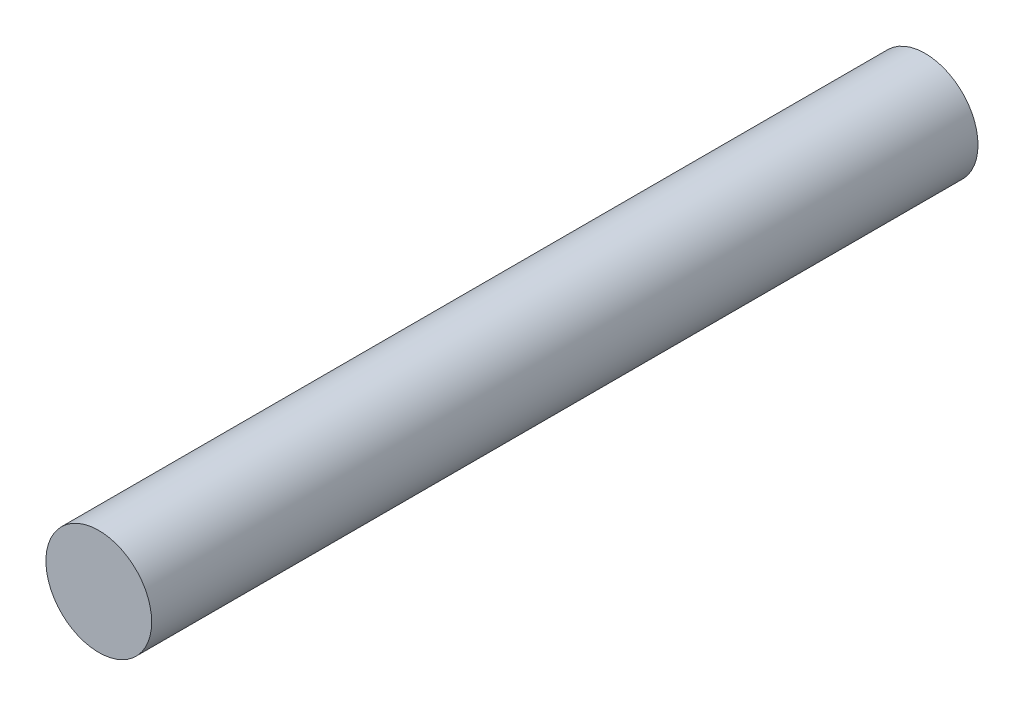
from build123d import *

# Parameters (mm, degrees)
SKETCH1_R           = 1.6
BOSS_EXTRUDE1_DEPTH = 12.5


with BuildPart() as part:
    # Sketch1 → Boss-Extrude1 (new body, symmetric)
    with BuildSketch(Plane.XY):
        Circle(SKETCH1_R)
    extrude(amount=BOSS_EXTRUDE1_DEPTH, both=True)


solid = part.part
